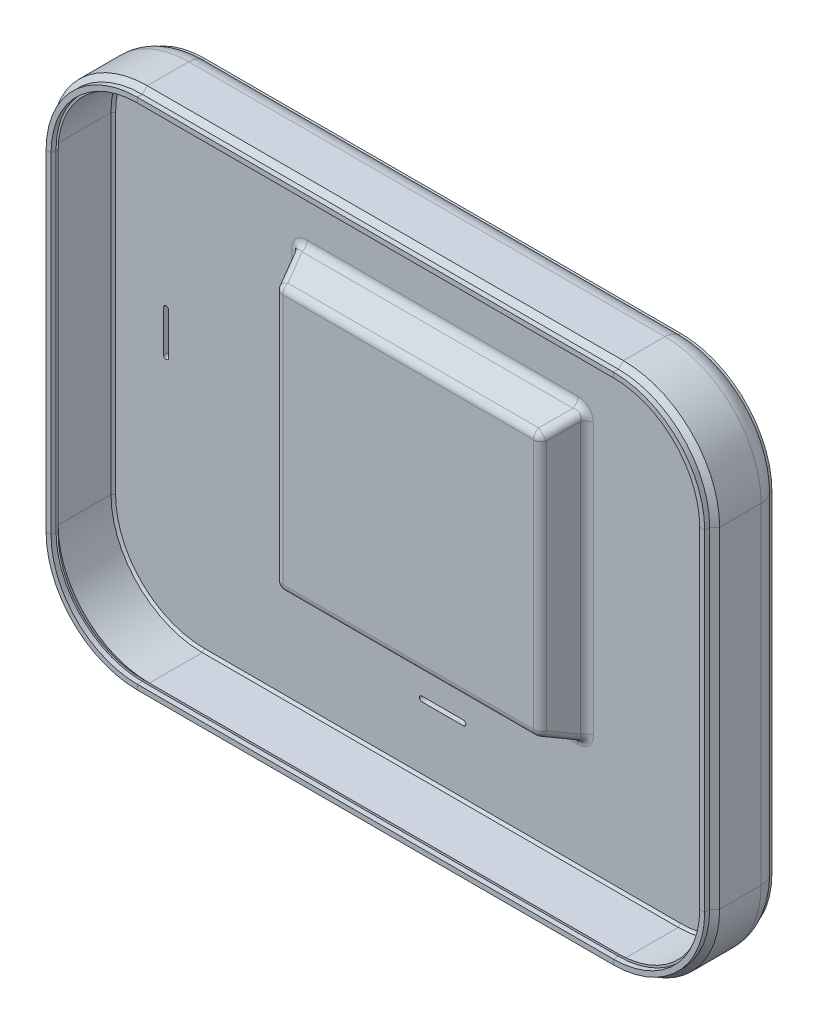
from build123d import *

# Parameters (mm, degrees)
BOSS_EXTRUDE1_DEPTH = 2.4
FILLET1_R           = 10
SKETCH2_W           = 140
SKETCH2_H           = 140
BOSS_EXTRUDE2_DEPTH = 16.6
BOSS_EXTRUDE2_TAPER = 22.5
SKETCH3_W           = 135.2
SKETCH3_H           = 135.2
CUT_EXTRUDE1_DEPTH  = 16.6
CUT_EXTRUDE1_TAPER  = 22.5
FILLET2_R           = 4
BOSS_EXTRUDE3_REACH = 36.8
CUT_EXTRUDE2_DEPTH  = 35.8


with BuildPart() as part:
    # Sweep2: sweep along a path in BasketRing
    with BuildLine(Plane.XY) as sweep2_path:
        Line((44, 0), (273.5, 0))
        ThreePointArc((273.5, 0), (304.612698372, 12.887301628), (317.5, 44))
        Line((317.5, 44), (317.5, 203.5))
        ThreePointArc((317.5, 203.5), (304.612698372, 234.612698372), (273.5, 247.5))
        Line((273.5, 247.5), (44, 247.5))
        ThreePointArc((44, 247.5), (12.887301628, 234.612698372), (0, 203.5))
        Line((0, 203.5), (0, 44))
        ThreePointArc((0, 44), (12.887301628, 12.887301628), (44, 0))
    # ShapeOf Edge → Sweep2 (sweep)
    with BuildSketch(Plane(origin=(44, 0, 0), x_dir=(0, 0, -1), z_dir=(1, 0, 0))):
        Polygon((0, 0), (2.4, 0), (4.8, -2.4), (34.8, -2.4), (34.8, 0), (5.79411255, 0), (2.4, 3.39411255), (2.4, 2.4), (0, 2.4), align=None)
    sweep(path=sweep2_path.line)

    # Sketch1 → Boss-Extrude1 (add)
    with BuildSketch(Plane(origin=(0, 0, -34.8), x_dir=(-1, 0, 0), z_dir=(0, 0, -1))):
        with BuildLine():
            Line((-273.5, 0), (-44, 0))
            ThreePointArc((-44, 0), (-12.887301628, 12.887301628), (0, 44))
            Line((0, 44), (0, 203.5))
            ThreePointArc((0, 203.5), (-12.887301628, 234.612698372), (-44, 247.5))
            Line((-44, 247.5), (-273.5, 247.5))
            ThreePointArc((-273.5, 247.5), (-304.612698372, 234.612698372), (-317.5, 203.5))
            Line((-317.5, 203.5), (-317.5, 44))
            ThreePointArc((-317.5, 44), (-304.612698372, 12.887301628), (-273.5, 0))
        make_face()
    extrude(amount=-BOSS_EXTRUDE1_DEPTH)

    # Fillet1
    fillet1_edges = [part.edges().sort_by_distance(p)[0] for p in [
        (11.190245353, 11.190245353, -34.8),
        (158.75, -2.4, -34.8),
        (306.309754647, 11.190245353, -34.8),
        (319.9, 123.75, -34.8),
        (306.309754647, 236.309754647, -34.8),
        (158.75, 249.9, -34.8),
        (11.190245353, 236.309754647, -34.8),
        (-2.4, 123.75, -34.8),
    ]]
    fillet(fillet1_edges, radius=FILLET1_R)

    # Sketch2 → Boss-Extrude2 (add)
    with BuildSketch(Plane(origin=(0, 0, -32.4), x_dir=(-1, 0, 0), z_dir=(0, 0, -1))):
        with Locations((-158.75, 123.75)):
            Rectangle(SKETCH2_W, SKETCH2_H)
    extrude(amount=-BOSS_EXTRUDE2_DEPTH, taper=BOSS_EXTRUDE2_TAPER)

    # Sketch3 → Cut-Extrude1 (cut)
    with BuildSketch(Plane(origin=(0, 0, -34.8), x_dir=(-1, 0, 0), z_dir=(0, 0, -1))):
        with Locations((-158.75, 123.75)):
            Rectangle(SKETCH3_W, SKETCH3_H)
    extrude(amount=-CUT_EXTRUDE1_DEPTH, taper=CUT_EXTRUDE1_TAPER, mode=Mode.SUBTRACT)

    # Fillet2
    fillet2_edges = [part.edges().sort_by_distance(p)[0] for p in [
        (221.874054865, 123.75, -15.8),
        (225.312027432, 57.187972568, -24.1),
        (158.75, 186.874054865, -15.8),
        (225.312027432, 190.312027432, -24.1),
        (95.625945135, 123.75, -15.8),
        (92.187972568, 190.312027432, -24.1),
        (158.75, 60.625945135, -15.8),
        (92.187972568, 57.187972568, -24.1),
        (228.75, 123.75, -32.4),
        (158.75, 53.75, -32.4),
        (88.75, 123.75, -32.4),
        (158.75, 193.75, -32.4),
        (219.474054865, 123.75, -18.2),
        (158.75, 184.474054865, -18.2),
        (98.025945135, 123.75, -18.2),
        (158.75, 63.025945135, -18.2),
        (226.35, 123.75, -34.8),
        (158.75, 56.15, -34.8),
        (91.15, 123.75, -34.8),
        (158.75, 191.35, -34.8),
    ]]
    fillet(fillet2_edges, radius=FILLET2_R)

    # Sketch4 → Boss-Extrude3 (add, up to next)
    with BuildSketch(Plane(origin=(0, 0, -34.8), x_dir=(-1, 0, 0), z_dir=(0, 0, -1)), mode=Mode.PRIVATE) as boss_extrude3_sk1:
        Polygon((-229.022714552, 138.75), (-88.477285448, 138.75), (-88.477285448, 136.35), (-157.55, 136.35), (-157.55, 111.15), (-88.477285448, 111.15), (-88.477285448, 108.75), (-229.022714552, 108.75), (-229.022714552, 111.15), (-159.95, 111.15), (-159.95, 136.35), (-229.022714552, 136.35), align=None)
    boss_extrude3_tool1 = extrude(boss_extrude3_sk1.sketch, amount=-BOSS_EXTRUDE3_REACH, mode=Mode.PRIVATE) - part.part
    add(boss_extrude3_tool1.solids().sort_by_distance((158.75, 123.75, -34.8))[0])

    # Sketch5 → Cut-Extrude2 (cut, through all)
    with BuildSketch(Plane(origin=(0, 0, -34.8), x_dir=(-1, 0, 0), z_dir=(0, 0, -1))):
        with BuildLine():
            Line((-168.75, 216.222714552), (-148.75, 216.222714552))
            ThreePointArc((-148.75, 216.222714552), (-147.55, 215.022714552), (-148.75, 213.822714552))
            Line((-148.75, 213.822714552), (-168.75, 213.822714552))
            ThreePointArc((-168.75, 213.822714552), (-169.95, 215.022714552), (-168.75, 216.222714552))
        make_face()
        with BuildLine():
            Line((-24.277285448, 133.75), (-24.277285448, 113.75))
            ThreePointArc((-24.277285448, 113.75), (-25.477285448, 112.55), (-26.677285448, 113.75))
            Line((-26.677285448, 113.75), (-26.677285448, 133.75))
            ThreePointArc((-26.677285448, 133.75), (-25.477285448, 134.95), (-24.277285448, 133.75))
        make_face()
        with BuildLine():
            Line((-290.822714552, 133.75), (-290.822714552, 113.75))
            ThreePointArc((-290.822714552, 113.75), (-292.022714552, 112.55), (-293.222714552, 113.75))
            Line((-293.222714552, 113.75), (-293.222714552, 133.75))
            ThreePointArc((-293.222714552, 133.75), (-292.022714552, 134.95), (-290.822714552, 133.75))
        make_face()
        with BuildLine():
            Line((-168.75, 33.677285448), (-148.75, 33.677285448))
            ThreePointArc((-148.75, 33.677285448), (-147.55, 32.477285448), (-148.75, 31.277285448))
            Line((-148.75, 31.277285448), (-168.75, 31.277285448))
            ThreePointArc((-168.75, 31.277285448), (-169.95, 32.477285448), (-168.75, 33.677285448))
        make_face()
    extrude(amount=-CUT_EXTRUDE2_DEPTH, mode=Mode.SUBTRACT)


solid = part.part
